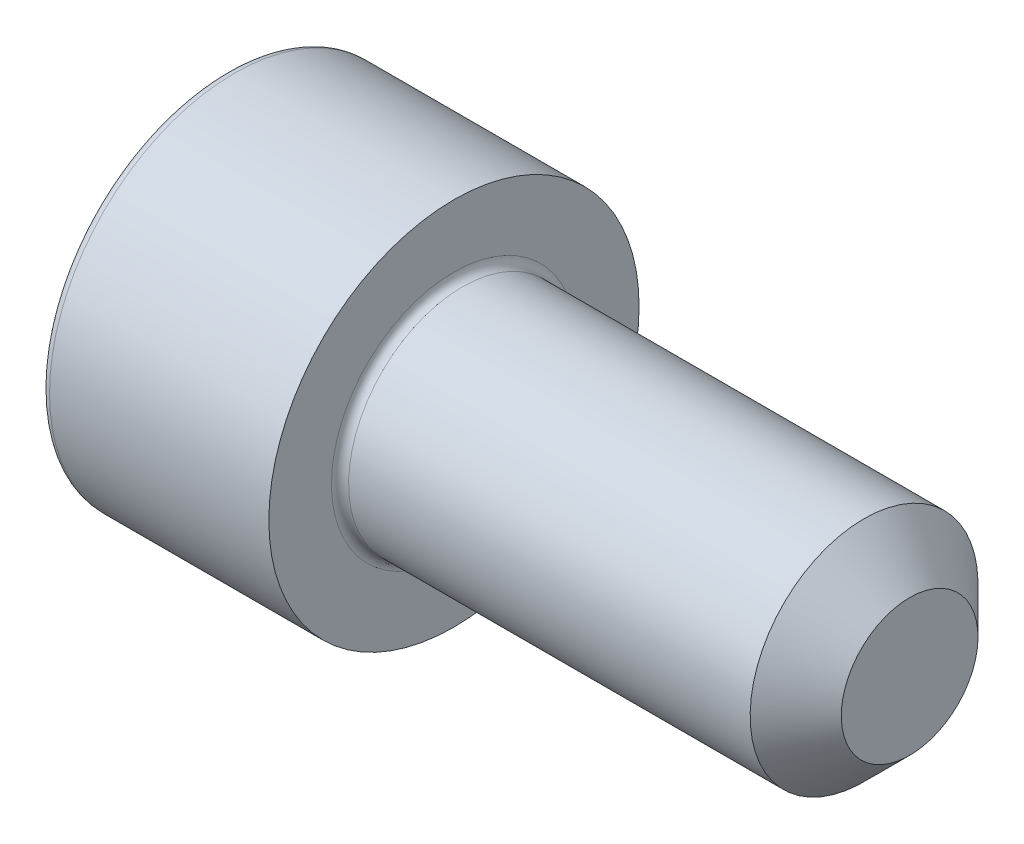
from build123d import *

# Parameters (mm, degrees)
CUT_EXTRUDE_1_DEPTH = 2.5
FILLET_1_R          = 0.3
CHAMFER_1_SIZE      = 1.6


with BuildPart() as part:
    # Эскиз1 → Повернуть1 (revolve)
    with BuildSketch(Plane.XY):
        Polygon((0, 0), (0, 6.5), (8, 6.5), (8, 4), (24, 4), (24, 0), align=None)
    revolve(axis=Axis((24, 0, 0), (-1, 0, 0)))

    # Эскиз2 → Вырез-Вытянуть1 (cut)
    with BuildSketch(Plane.ZY):
        Polygon((-1.732050808, 3), (-3.464101615, 0), (-1.732050808, -3), (1.732050808, -3), (3.464101615, 0), (1.732050808, 3), align=None)
    extrude(amount=-CUT_EXTRUDE_1_DEPTH, mode=Mode.SUBTRACT)

    # Скругление1
    fillet_1_edges = [part.edges().sort_by_distance(p)[0] for p in [
        (8, -4, 0),
        (0, -6.5, 0),
    ]]
    fillet(fillet_1_edges, radius=FILLET_1_R)

    # Фаска1
    chamfer_1_edges = [part.edges().sort_by_distance(p)[0] for p in [
        (24, -4, 0),
    ]]
    chamfer(chamfer_1_edges, length=CHAMFER_1_SIZE)


solid = part.part
